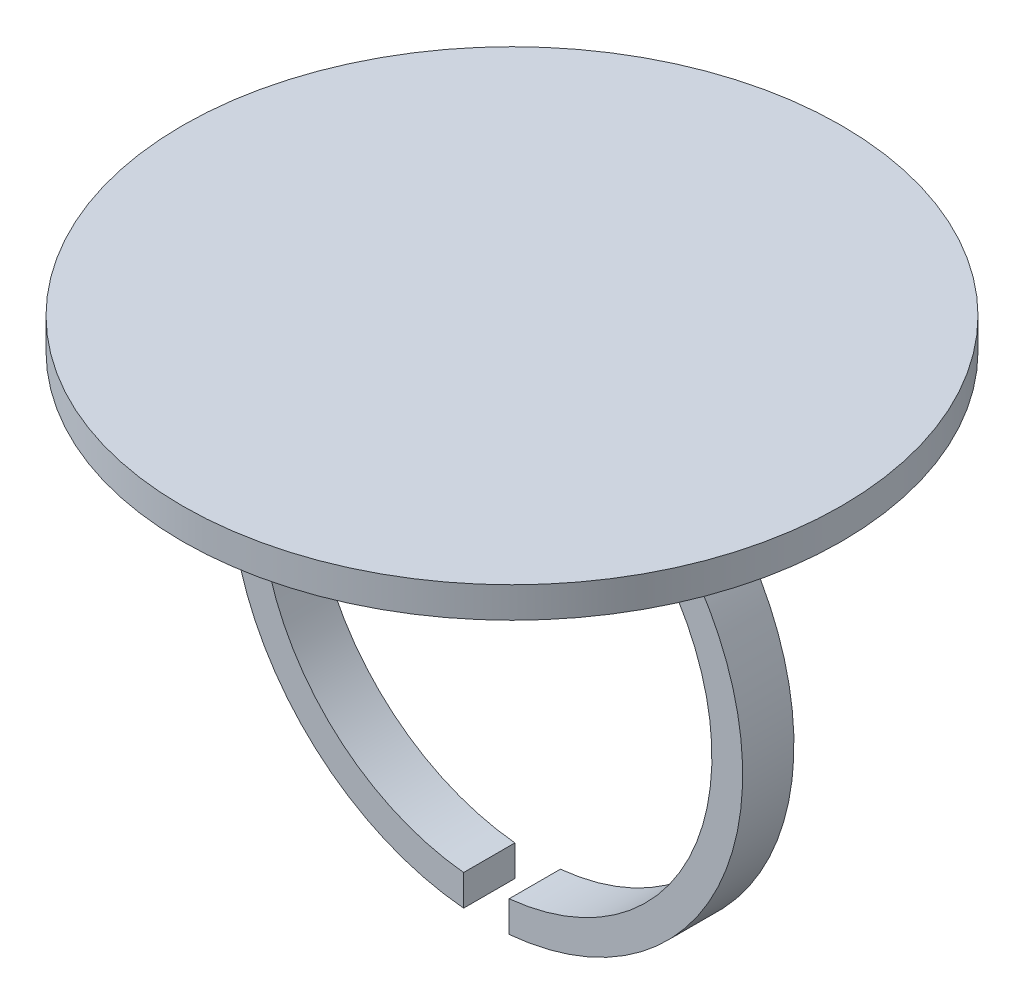
from build123d import *

# Parameters (mm, degrees)
ESQUISSE1_R             = 32.139129067
BOSS_EXTRU_1_DEPTH      = 3
BOSS_EXTRU_2_DEPTH      = 2.5
BOSS_EXTRU_2_DEPTH_BACK = 2.5
ESQUISSE2_R             = 25
ESQUISSE3_R             = 22
ENL_V_MAT_EXTRU_1_DEPTH = 5
ESQUISSE7_W             = 4.438304304
ESQUISSE7_H             = 8.275677871
ENL_V_MAT_EXTRU_4_DEPTH = 5


with BuildPart() as part:
    # Esquisse1 → Boss.-Extru.1 (new body)
    with BuildSketch(Plane(origin=(0, 0, 0), x_dir=(1, 0, 0), z_dir=(0, 1, 0))):
        Circle(ESQUISSE1_R)
    extrude(amount=BOSS_EXTRU_1_DEPTH)

    # Esquisse2 → Boss.-Extru.2 (add, two sides: drawn at the far end of the back side and taken through both)
    with BuildSketch(Plane.XY.offset(-BOSS_EXTRU_2_DEPTH_BACK)):
        with Locations((0, -22)):
            Circle(ESQUISSE2_R)
    extrude(amount=BOSS_EXTRU_2_DEPTH + BOSS_EXTRU_2_DEPTH_BACK)

    # Esquisse3 → Enlèv. mat.-Extru.1 (cut)
    with BuildSketch(Plane.XY.offset(2.5)):
        with Locations((0, -22)):
            Circle(ESQUISSE3_R)
    extrude(amount=-ENL_V_MAT_EXTRU_1_DEPTH, mode=Mode.SUBTRACT)

    # Esquisse7 → Enlèv. mat.-Extru.4 (cut)
    with BuildSketch(Plane.XY.offset(2.5)):
        with Locations((0, -45.862161065)):
            Rectangle(ESQUISSE7_W, ESQUISSE7_H)
    extrude(amount=-ENL_V_MAT_EXTRU_4_DEPTH, mode=Mode.SUBTRACT)


solid = part.part
